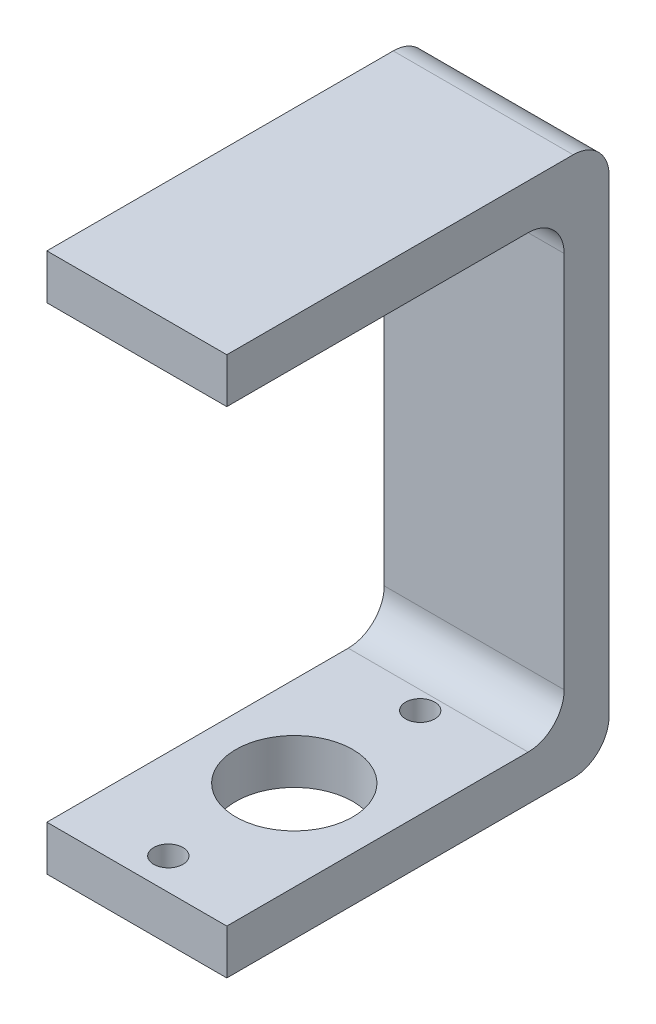
from build123d import *

# Parameters (mm, degrees)
EXTRUDE_1_DEPTH     = 40
CUT_EXTRUDE_1_REACH = 122
SKETCH_5_R          = 13
SKETCH_6_R          = 3.25
CUT_EXTRUDE_2_DEPTH = 20


with BuildPart() as part:
    # 草图1 → 凸台-拉伸1 (new body)
    with BuildSketch(Plane(origin=(0, 0, 0), x_dir=(0, 0, -1), z_dir=(1, 0, 0))):
        with BuildLine():
            Line((0, 0), (77, 0))
            ThreePointArc((77, 0), (82.656854249, 2.343145751), (85, 8))
            Line((85, 8), (85, 112))
            ThreePointArc((85, 112), (82.656854249, 117.656854249), (77, 120))
            Line((77, 120), (0, 120))
            Line((0, 120), (0, 110))
            Line((0, 110), (67, 110))
            ThreePointArc((67, 110), (72.656854249, 107.656854249), (75, 102))
            Line((75, 102), (75, 18))
            ThreePointArc((75, 18), (72.656854249, 12.343145751), (67, 10))
            Line((67, 10), (0, 10))
            Line((0, 10), (0, 0))
        make_face()
    extrude(amount=EXTRUDE_1_DEPTH)

    # 草图5 → 切除-拉伸1 (cut, up to next)
    with BuildSketch(Plane.XZ, mode=Mode.PRIVATE) as cut_extrude_1_sk1:
        with Locations((20, -35)):
            Circle(SKETCH_5_R)
    cut_extrude_1_tool1 = extrude(cut_extrude_1_sk1.sketch, amount=-CUT_EXTRUDE_1_REACH, mode=Mode.PRIVATE) & part.part
    add(cut_extrude_1_tool1.solids().sort_by_distance((20, 0, -35))[0], mode=Mode.SUBTRACT)

    # 草图6 → 切除-拉伸2 (cut)
    with BuildSketch(Plane.XZ):
        with Locations((20, -7)):
            Circle(SKETCH_6_R)
        with Locations((20, -63)):
            Circle(SKETCH_6_R)
    extrude(amount=-CUT_EXTRUDE_2_DEPTH, mode=Mode.SUBTRACT)


solid = part.part
